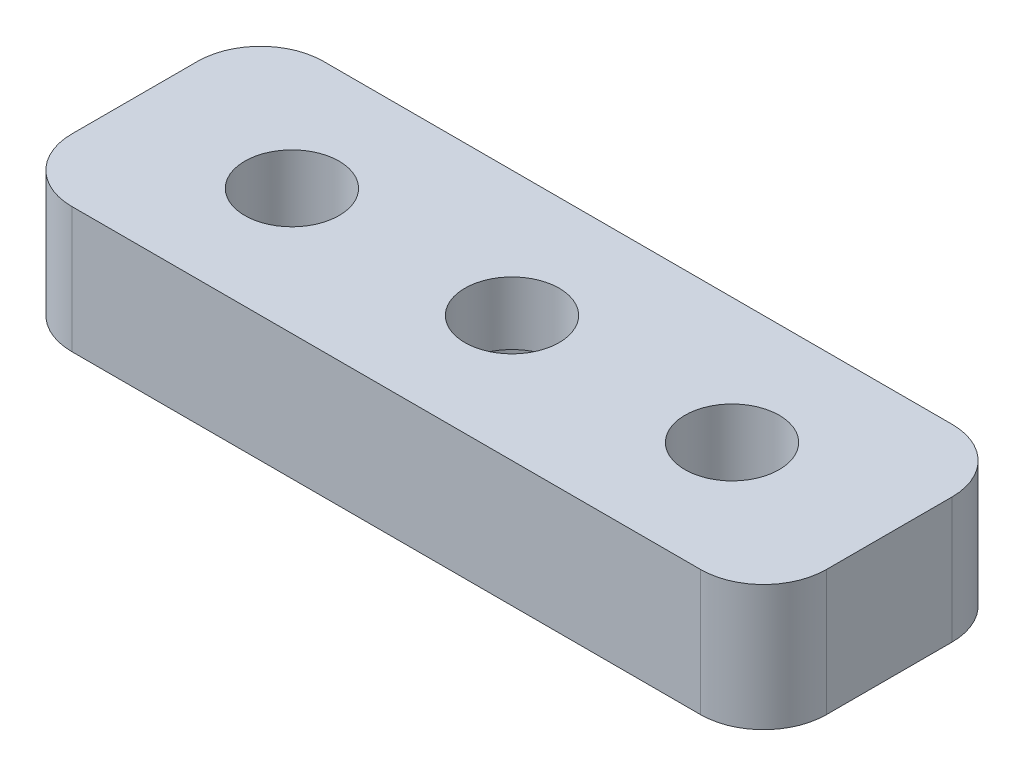
from build123d import *

# Parameters (mm, degrees)
BOSS_EXTRUDE1_DEPTH = 4
CUT_EXTRUDE1_REACH  = 15.266
SKETCH1_3_R         = 1.5
SKETCH1_4_R         = 2.5
CUT_EXTRUDE2_DEPTH  = 2


with BuildPart() as part:
    # Sketch1 → Boss-Extrude1 (new body)
    with BuildSketch(Plane(origin=(0, 0, 0), x_dir=(1, 0, 0), z_dir=(0, 1, 0))):
        with BuildLine():
            Line((0, 4), (10, 4))
            ThreePointArc((10, 4), (11.414213562, 3.414213562), (12, 2))
            Line((12, 2), (12, -2))
            ThreePointArc((12, -2), (11.414213562, -3.414213562), (10, -4))
            Line((10, -4), (0, -4))
            Line((0, -4), (-10, -4))
            ThreePointArc((-10, -4), (-11.414213562, -3.414213562), (-12, -2))
            Line((-12, -2), (-12, 2))
            ThreePointArc((-12, 2), (-11.414213562, 3.414213562), (-10, 4))
            Line((-10, 4), (0, 4))
        make_face()
    extrude(amount=BOSS_EXTRUDE1_DEPTH)

    # Sketch1_3 → Cut-Extrude1 (cut, up to next)
    with BuildSketch(Plane(origin=(0, 0, 0), x_dir=(1, 0, 0), z_dir=(0, 1, 0)), mode=Mode.PRIVATE) as cut_extrude1_sk1:
        Circle(SKETCH1_3_R)
    cut_extrude1_tool1 = extrude(cut_extrude1_sk1.sketch, amount=CUT_EXTRUDE1_REACH, mode=Mode.PRIVATE) & part.part
    # Sketch1_3 → Cut-Extrude1 (cut, up to next)
    with BuildSketch(Plane(origin=(0, 0, 0), x_dir=(1, 0, 0), z_dir=(0, 1, 0)), mode=Mode.PRIVATE) as cut_extrude1_sk2:
        with Locations((-7, 0)):
            Circle(SKETCH1_3_R)
    cut_extrude1_tool2 = extrude(cut_extrude1_sk2.sketch, amount=CUT_EXTRUDE1_REACH, mode=Mode.PRIVATE) & part.part
    # Sketch1_3 → Cut-Extrude1 (cut, up to next)
    with BuildSketch(Plane(origin=(0, 0, 0), x_dir=(1, 0, 0), z_dir=(0, 1, 0)), mode=Mode.PRIVATE) as cut_extrude1_sk3:
        with Locations((7, 0)):
            Circle(SKETCH1_3_R)
    cut_extrude1_tool3 = extrude(cut_extrude1_sk3.sketch, amount=CUT_EXTRUDE1_REACH, mode=Mode.PRIVATE) & part.part
    add(cut_extrude1_tool1.solids().sort_by_distance((0, 0, 0))[0], mode=Mode.SUBTRACT)
    add(cut_extrude1_tool2.solids().sort_by_distance((-7, 0, 0))[0], mode=Mode.SUBTRACT)
    add(cut_extrude1_tool3.solids().sort_by_distance((7, 0, 0))[0], mode=Mode.SUBTRACT)

    # Sketch1_4 → Cut-Extrude2 (cut)
    with BuildSketch(Plane(origin=(0, 0, 0), x_dir=(1, 0, 0), z_dir=(0, 1, 0))):
        Circle(SKETCH1_4_R)
    extrude(amount=CUT_EXTRUDE2_DEPTH, mode=Mode.SUBTRACT)


solid = part.part
